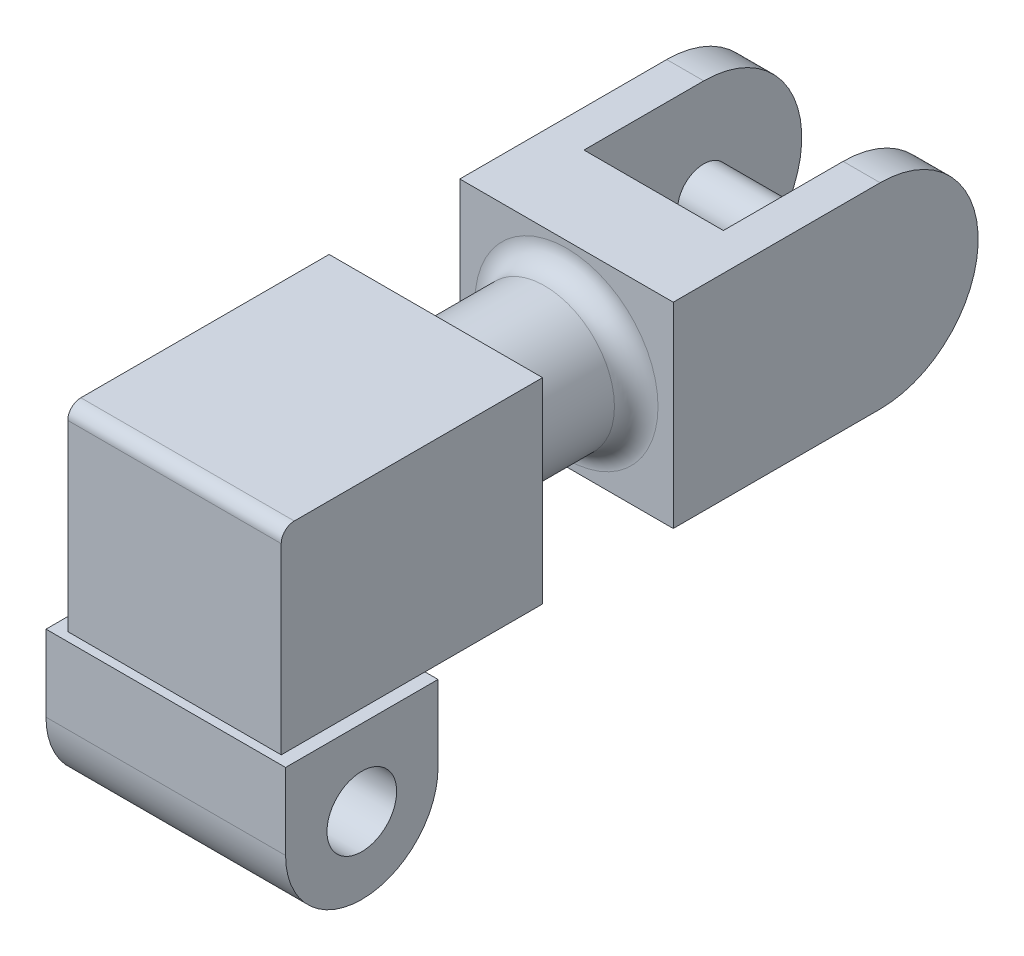
from build123d import *

# Parameters (mm, degrees)
SKETCH1_R           = 8
BOSS_EXTRUDE1_DEPTH = 27.5
SKETCH2_W           = 49
SKETCH2_H           = 60
BOSS_EXTRUDE2_DEPTH = 45
SKETCH3_R           = 16
BOSS_EXTRUDE3_DEPTH = 30
SKETCH4_W           = 49
SKETCH4_H           = 45
BOSS_EXTRUDE4_DEPTH = 47.5
BOSS_EXTRUDE5_DEPTH = 49
SKETCH6_W           = 24.794244746
SKETCH6_H           = 50
CUT_EXTRUDE1_DEPTH  = 81
SKETCH7_R           = 6
CUT_EXTRUDE2_DEPTH  = 53
SKETCH8_R           = 6
BOSS_EXTRUDE6_DEPTH = 49
FILLET1_R           = 5
FILLET2_R           = 5
FILLET4_R           = 3
CUT_EXTRUDE4_DEPTH  = 81
SKETCH12_R          = 6
BOSS_EXTRUDE7_DEPTH = 32


with BuildPart() as part:
    # Sketch1 → Boss-Extrude1 (new body, symmetric)
    with BuildSketch(Plane(origin=(0, 0, 0), x_dir=(0, 0, -1), z_dir=(1, 0, 0))):
        with BuildLine():
            Line((-17.5, 0), (-17.5, 17.5))
            Line((-17.5, 17.5), (17.5, 17.5))
            Line((17.5, 17.5), (17.5, 0))
            ThreePointArc((17.5, 0), (0, -17.5), (-17.5, 0))
        make_face()
        Circle(SKETCH1_R, mode=Mode.SUBTRACT)
    extrude(amount=BOSS_EXTRUDE1_DEPTH, both=True)

    # Sketch2 → Boss-Extrude2 (add)
    with BuildSketch(Plane(origin=(0, 17.5, 0), x_dir=(1, 0, 0), z_dir=(0, 1, 0))):
        with Locations((0, 14.5)):
            Rectangle(SKETCH2_W, SKETCH2_H)
    extrude(amount=BOSS_EXTRUDE2_DEPTH)

    # Sketch3 → Boss-Extrude3 (add)
    with BuildSketch(Plane(origin=(0, 0, -44.5), x_dir=(-1, 0, 0), z_dir=(0, 0, -1))):
        with Locations((0, 40)):
            Circle(SKETCH3_R)
    extrude(amount=BOSS_EXTRUDE3_DEPTH)

    # Sketch4 → Boss-Extrude4 (add)
    with BuildSketch(Plane(origin=(0, 0, -74.5), x_dir=(-1, 0, 0), z_dir=(0, 0, -1))):
        with Locations((0, 40)):
            Rectangle(SKETCH4_W, SKETCH4_H)
    extrude(amount=BOSS_EXTRUDE4_DEPTH)

    # Sketch5 → Boss-Extrude5 (add)
    with BuildSketch(Plane(origin=(24.5, 0, 0), x_dir=(0, 0, -1), z_dir=(1, 0, 0))):
        with BuildLine():
            Line((122, 62.5), (122, 17.5))
            ThreePointArc((122, 17.5), (144.5, 40), (122, 62.5))
        make_face()
    extrude(amount=-BOSS_EXTRUDE5_DEPTH)

    # Sketch6 → Cut-Extrude1 (cut, through all)
    with BuildSketch(Plane(origin=(0, 62.5, 0), x_dir=(1, 0, 0), z_dir=(0, 1, 0))):
        with Locations((0, 119.5)):
            Rectangle(SKETCH6_W, SKETCH6_H)
    extrude(amount=-CUT_EXTRUDE1_DEPTH, mode=Mode.SUBTRACT)

    # Sketch7 → Cut-Extrude2 (cut, through all)
    with BuildSketch(Plane(origin=(24.5, 0, 0), x_dir=(0, 0, -1), z_dir=(1, 0, 0))):
        with Locations((122, 40)):
            Circle(SKETCH7_R)
    extrude(amount=-CUT_EXTRUDE2_DEPTH, mode=Mode.SUBTRACT)

    # Sketch8 → Boss-Extrude6 (add)
    with BuildSketch(Plane(origin=(24.5, 0, 0), x_dir=(0, 0, -1), z_dir=(1, 0, 0))):
        with Locations((122, 40)):
            Circle(SKETCH8_R)
    extrude(amount=-BOSS_EXTRUDE6_DEPTH)

    # Fillet1
    fillet1_edges = [part.edges().sort_by_distance(p)[0] for p in [
        (16, 40, -44.5),
    ]]
    fillet(fillet1_edges, radius=FILLET1_R)

    # Fillet2
    fillet2_edges = [part.edges().sort_by_distance(p)[0] for p in [
        (16, 40, -74.5),
    ]]
    fillet(fillet2_edges, radius=FILLET2_R)

    # Fillet4
    fillet4_edges = [part.edges().sort_by_distance(p)[0] for p in [
        (0, 62.5, 15.5),
    ]]
    fillet(fillet4_edges, radius=FILLET4_R)

    # Sketch10 → Cut-Extrude4 (cut, through all)
    with BuildSketch(Plane(origin=(0, 62.5, 0), x_dir=(1, 0, 0), z_dir=(0, 1, 0))):
        Polygon((16, 94.5), (16, 144.5), (-16, 144.5), (-16, 97.685176626), (-16, 94.5), align=None)
    extrude(amount=-CUT_EXTRUDE4_DEPTH, mode=Mode.SUBTRACT)

    # Sketch12 → Boss-Extrude7 (add)
    with BuildSketch(Plane.ZY.offset(-16)):
        with Locations((-122, 40)):
            Circle(SKETCH12_R)
    extrude(amount=BOSS_EXTRUDE7_DEPTH)


solid = part.part
